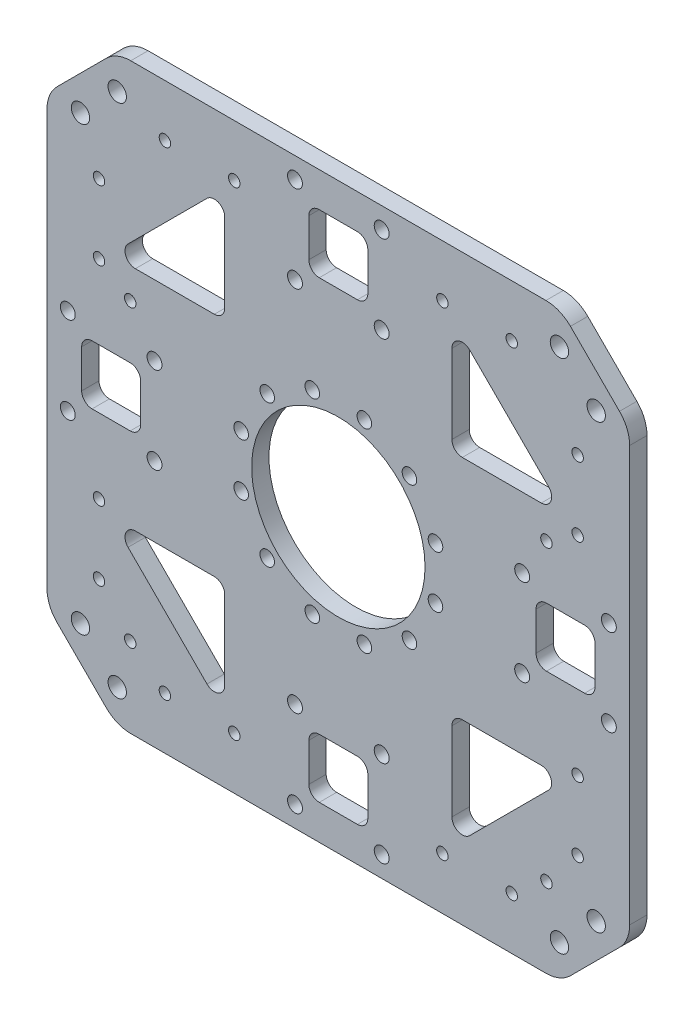
from build123d import *

# Parameters (mm, degrees)
SKETCH_1_W               = 168
SKETCH_1_H               = 168
EXTRUDE_1_DEPTH          = 5
CUT_EXTRUDE_1_DEPTH      = 6
SKETCH_3_R               = 2.1
SKETCH_3_R_2             = 25
CUT_EXTRUDE_2_DEPTH      = 6
PATTERN_CIRCULAR_1_COUNT = 12
SKETCH_5_R               = 2.65
CUT_EXTRUDE_4_DEPTH      = 6
PATTERN_CIRCULAR_2_COUNT = 4
FILLET_1_R               = 10
SKETCH_6_R               = 2.15
CUT_EXTRUDE_5_DEPTH      = 6
PATTERN_CIRCULAR_3_COUNT = 4
SKETCH_7_R               = 1.65
CUT_EXTRUDE_6_DEPTH      = 6
CUT_EXTRUDE_7_DEPTH      = 6
PATTERN_CIRCULAR_4_COUNT = 4
FILLET_2_R               = 3
SKETCH_9_R               = 1.65
CUT_EXTRUDE_8_DEPTH      = 6


with BuildPart() as part:
    # 草图1 → 凸台-拉伸1 (new body)
    with BuildSketch(Plane.XY):
        Rectangle(SKETCH_1_W, SKETCH_1_H)
    extrude(amount=EXTRUDE_1_DEPTH)

    # 草图2 → 切除-拉伸1 (cut, through all)
    with BuildSketch(Plane.XY.offset(5)):
        Polygon((64, 84), (84, 64), (84, 84), align=None)
        Polygon((64, -84), (84, -84), (84, -64), align=None)
        Polygon((-84, -64), (-84, -84), (-64, -84), align=None)
        Polygon((-64, 84), (-84, 84), (-84, 64), align=None)
    extrude(amount=-CUT_EXTRUDE_1_DEPTH, mode=Mode.SUBTRACT)

    # 草图3 → 切除-拉伸2 (cut, through all)
    with BuildSketch(Plane.XY.offset(5)):
        with Locations((7.505752308, 28.011848962)):
            Circle(SKETCH_3_R)
        Circle(SKETCH_3_R_2)
    cut_extrude_2 = extrude(amount=-CUT_EXTRUDE_2_DEPTH, mode=Mode.SUBTRACT)

    # 阵列(圆周)1: 切除-拉伸2 ×12 about axis
    pattern_circular_1_axis = Axis((0, 0, 0), (0, 0, 1))
    for i in range(1, PATTERN_CIRCULAR_1_COUNT):
        add(cut_extrude_2.rotate(pattern_circular_1_axis, i * 360 / PATTERN_CIRCULAR_1_COUNT), mode=Mode.SUBTRACT)

    # 草图5 → 切除-拉伸4 (cut, through all)
    with BuildSketch(Plane(origin=(0, 0, 0), x_dir=(-1, 0, 0), z_dir=(0, 0, -1))):
        with Locations((63.746951673, 74.353553391)):
            Circle(SKETCH_5_R)
        with Locations((74.353553391, 63.746951673)):
            Circle(SKETCH_5_R)
    cut_extrude_4 = extrude(amount=-CUT_EXTRUDE_4_DEPTH, mode=Mode.SUBTRACT)

    # 阵列(圆周)2: 切除-拉伸4 ×4 about axis
    pattern_circular_2_axis = Axis((0, 0, 0), (0, 0, 1))
    for i in range(1, PATTERN_CIRCULAR_2_COUNT):
        add(cut_extrude_4.rotate(pattern_circular_2_axis, i * 360 / PATTERN_CIRCULAR_2_COUNT), mode=Mode.SUBTRACT)

    # 圆角1
    fillet_1_edges = [part.edges().sort_by_distance(p)[0] for p in [
        (-64, 84, 2.5),
        (-84, 64, 2.5),
        (-84, -64, 2.5),
        (-64, -84, 2.5),
        (64, -84, 2.5),
        (84, -64, 2.5),
        (64, 84, 2.5),
        (84, 64, 2.5),
    ]]
    fillet(fillet_1_edges, radius=FILLET_1_R)

    # 草图6 → 切除-拉伸5 (cut, through all)
    with BuildSketch(Plane(origin=(0, 0, 0), x_dir=(-1, 0, 0), z_dir=(0, 0, -1))):
        with Locations((-12.5, 78)):
            Circle(SKETCH_6_R)
        with Locations((12.5, 78)):
            Circle(SKETCH_6_R)
        with Locations((12.5, 53)):
            Circle(SKETCH_6_R)
        with Locations((-12.5, 53)):
            Circle(SKETCH_6_R)
        with BuildLine():
            Line((-8.5, 71), (-8.5, 60))
            ThreePointArc((-8.5, 60), (-7.621320344, 57.878679656), (-5.5, 57))
            Line((-5.5, 57), (5.5, 57))
            ThreePointArc((5.5, 57), (7.621320344, 57.878679656), (8.5, 60))
            Line((8.5, 60), (8.5, 71))
            ThreePointArc((8.5, 71), (7.621320344, 73.121320344), (5.5, 74))
            Line((5.5, 74), (-5.5, 74))
            ThreePointArc((-5.5, 74), (-7.621320344, 73.121320344), (-8.5, 71))
        make_face()
    cut_extrude_5 = extrude(amount=-CUT_EXTRUDE_5_DEPTH, mode=Mode.SUBTRACT)

    # 阵列(圆周)3: 切除-拉伸5 ×4 about axis
    pattern_circular_3_axis = Axis((0, 0, 0), (0, 0, 1))
    for i in range(1, PATTERN_CIRCULAR_3_COUNT):
        add(cut_extrude_5.rotate(pattern_circular_3_axis, i * 360 / PATTERN_CIRCULAR_3_COUNT), mode=Mode.SUBTRACT)

    # 草图7 → 切除-拉伸6 (cut, through all)
    with BuildSketch(Plane(origin=(0, 0, 0), x_dir=(-1, 0, 0), z_dir=(0, 0, -1))):
        with Locations((60, 24)):
            Circle(SKETCH_7_R)
        with Locations((-60, 24)):
            Circle(SKETCH_7_R)
        with Locations((-60, -61)):
            Circle(SKETCH_7_R)
        with Locations((60, -61)):
            Circle(SKETCH_7_R)
    extrude(amount=-CUT_EXTRUDE_6_DEPTH, mode=Mode.SUBTRACT)

    # 草图8 → 切除-拉伸7 (cut, through all)
    with BuildSketch(Plane(origin=(0, 0, 0), x_dir=(-1, 0, 0), z_dir=(0, 0, -1))):
        Polygon((32.75, 32.75), (32.75, 65.752525317), (65.752525317, 32.75), align=None)
    cut_extrude_7 = extrude(amount=-CUT_EXTRUDE_7_DEPTH, mode=Mode.SUBTRACT)

    # 阵列(圆周)4: 切除-拉伸7 ×4 about axis
    pattern_circular_4_axis = Axis((0, 0, 0), (0, 0, 1))
    for i in range(1, PATTERN_CIRCULAR_4_COUNT):
        add(cut_extrude_7.rotate(pattern_circular_4_axis, i * 360 / PATTERN_CIRCULAR_4_COUNT), mode=Mode.SUBTRACT)

    # 圆角2
    fillet_2_edges = [part.edges().sort_by_distance(p)[0] for p in [
        (-65.752525317, 32.75, 2.5),
        (-32.75, 32.75, 2.5),
        (-32.75, 65.752525317, 2.5),
        (-32.75, -65.752525317, 2.5),
        (-32.75, -32.75, 2.5),
        (-65.752525317, -32.75, 2.5),
        (65.752525317, -32.75, 2.5),
        (32.75, -32.75, 2.5),
        (32.75, -65.752525317, 2.5),
        (32.75, 65.752525317, 2.5),
        (32.75, 32.75, 2.5),
        (65.752525317, 32.75, 2.5),
    ]]
    fillet(fillet_2_edges, radius=FILLET_2_R)

    # 草图9 → 切除-拉伸8 (cut, through all)
    with BuildSketch(Plane(origin=(0, 0, 0), x_dir=(-1, 0, 0), z_dir=(0, 0, -1))):
        with Locations((-50, 69)):
            Circle(SKETCH_9_R)
        with Locations((-30, 69)):
            Circle(SKETCH_9_R)
        with Locations((30, 69)):
            Circle(SKETCH_9_R)
        with Locations((50, 69)):
            Circle(SKETCH_9_R)
        with Locations((69, 30)):
            Circle(SKETCH_9_R)
        with Locations((69, 50)):
            Circle(SKETCH_9_R)
        with Locations((69, -30)):
            Circle(SKETCH_9_R)
        with Locations((69, -50)):
            Circle(SKETCH_9_R)
        with Locations((-69, -30)):
            Circle(SKETCH_9_R)
        with Locations((-69, -50)):
            Circle(SKETCH_9_R)
        with Locations((-69, 30)):
            Circle(SKETCH_9_R)
        with Locations((-69, 50)):
            Circle(SKETCH_9_R)
        with Locations((-30, -69)):
            Circle(SKETCH_9_R)
        with Locations((-50, -69)):
            Circle(SKETCH_9_R)
        with Locations((30, -69)):
            Circle(SKETCH_9_R)
        with Locations((50, -69)):
            Circle(SKETCH_9_R)
    extrude(amount=-CUT_EXTRUDE_8_DEPTH, mode=Mode.SUBTRACT)


solid = part.part
